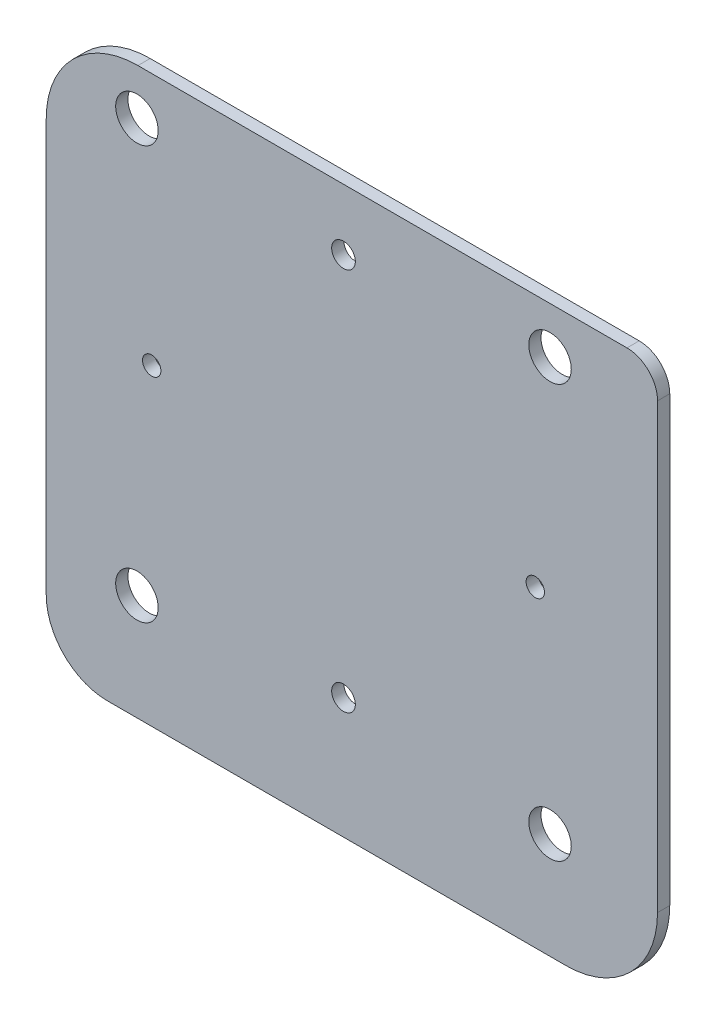
from build123d import *

# Parameters (mm, degrees)
BOSS_EXTRUDE1_DEPTH       = 1.6
CUT_EXTRUDE3_REACH        = 3.6
SKETCH3_R                 = 1.55
SKETCH3_R_2               = 1.2
CUT_EXTRUDE4_REACH        = 3.6
PRESS_FIT_NUT_LOCATIONS_R = 2.78


with BuildPart() as part:
    # Outline → Boss-Extrude1 (new body)
    with BuildSketch(Plane.XY):
        with BuildLine():
            Line((-38.9, 21.1), (-38.9, -32.9))
            ThreePointArc((-38.9, -32.9), (-36.556854249, -38.556854249), (-30.9, -40.9))
            Line((-30.9, -40.9), (29.1, -40.9))
            ThreePointArc((29.1, -40.9), (37.585281374, -37.385281374), (41.1, -28.9))
            Line((41.1, -28.9), (41.1, 29.1))
            ThreePointArc((41.1, 29.1), (39.928427125, 31.928427125), (37.1, 33.1))
            Line((37.1, 33.1), (-26.9, 33.1))
            ThreePointArc((-26.9, 33.1), (-35.385281374, 29.585281374), (-38.9, 21.1))
        make_face()
    extrude(amount=BOSS_EXTRUDE1_DEPTH)

    # Sketch3 → Cut-Extrude3 (cut, up to next)
    with BuildSketch(Plane.XY.offset(1.6), mode=Mode.PRIVATE) as cut_extrude3_sk1:
        with Locations((-6.677e-06, 25.099991446)):
            Circle(SKETCH3_R)
    cut_extrude3_tool1 = extrude(cut_extrude3_sk1.sketch, amount=-CUT_EXTRUDE3_REACH, mode=Mode.PRIVATE) & part.part
    add(cut_extrude3_tool1.solids().sort_by_distance((-7e-06, 25.099991, 1.6))[0], mode=Mode.SUBTRACT)
    # Sketch3 → Cut-Extrude3 (cut, up to next)
    with BuildSketch(Plane.XY.offset(1.6), mode=Mode.PRIVATE) as cut_extrude3_sk2:
        with Locations((25.099993323, -8.554e-06)):
            Circle(SKETCH3_R_2)
    cut_extrude3_tool2 = extrude(cut_extrude3_sk2.sketch, amount=-CUT_EXTRUDE3_REACH, mode=Mode.PRIVATE) & part.part
    add(cut_extrude3_tool2.solids().sort_by_distance((25.099993, -9e-06, 1.6))[0], mode=Mode.SUBTRACT)
    # Sketch3 → Cut-Extrude3 (cut, up to next)
    with BuildSketch(Plane.XY.offset(1.6), mode=Mode.PRIVATE) as cut_extrude3_sk3:
        with Locations((-6.677e-06, -25.100008554)):
            Circle(SKETCH3_R)
    cut_extrude3_tool3 = extrude(cut_extrude3_sk3.sketch, amount=-CUT_EXTRUDE3_REACH, mode=Mode.PRIVATE) & part.part
    add(cut_extrude3_tool3.solids().sort_by_distance((-7e-06, -25.100009, 1.6))[0], mode=Mode.SUBTRACT)
    # Sketch3 → Cut-Extrude3 (cut, up to next)
    with BuildSketch(Plane.XY.offset(1.6), mode=Mode.PRIVATE) as cut_extrude3_sk4:
        with Locations((-25.100006677, -8.554e-06)):
            Circle(SKETCH3_R_2)
    cut_extrude3_tool4 = extrude(cut_extrude3_sk4.sketch, amount=-CUT_EXTRUDE3_REACH, mode=Mode.PRIVATE) & part.part
    add(cut_extrude3_tool4.solids().sort_by_distance((-25.100007, -9e-06, 1.6))[0], mode=Mode.SUBTRACT)

    # Press Fit Nut Locations → Cut-Extrude4 (cut, up to next)
    with BuildSketch(Plane.XY.offset(1.6), mode=Mode.PRIVATE) as cut_extrude4_sk1:
        with Locations((-27.030733336, 27.030733336)):
            Circle(PRESS_FIT_NUT_LOCATIONS_R)
    cut_extrude4_tool1 = extrude(cut_extrude4_sk1.sketch, amount=-CUT_EXTRUDE4_REACH, mode=Mode.PRIVATE) & part.part
    add(cut_extrude4_tool1.solids().sort_by_distance((-27.030733, 27.030733, 1.6))[0], mode=Mode.SUBTRACT)
    # Press Fit Nut Locations → Cut-Extrude4 (cut, up to next)
    with BuildSketch(Plane.XY.offset(1.6), mode=Mode.PRIVATE) as cut_extrude4_sk2:
        with Locations((27.030733336, 27.030733336)):
            Circle(PRESS_FIT_NUT_LOCATIONS_R)
    cut_extrude4_tool2 = extrude(cut_extrude4_sk2.sketch, amount=-CUT_EXTRUDE4_REACH, mode=Mode.PRIVATE) & part.part
    add(cut_extrude4_tool2.solids().sort_by_distance((27.030733, 27.030733, 1.6))[0], mode=Mode.SUBTRACT)
    # Press Fit Nut Locations → Cut-Extrude4 (cut, up to next)
    with BuildSketch(Plane.XY.offset(1.6), mode=Mode.PRIVATE) as cut_extrude4_sk3:
        with Locations((-27.030733336, -27.030733336)):
            Circle(PRESS_FIT_NUT_LOCATIONS_R)
    cut_extrude4_tool3 = extrude(cut_extrude4_sk3.sketch, amount=-CUT_EXTRUDE4_REACH, mode=Mode.PRIVATE) & part.part
    add(cut_extrude4_tool3.solids().sort_by_distance((-27.030733, -27.030733, 1.6))[0], mode=Mode.SUBTRACT)
    # Press Fit Nut Locations → Cut-Extrude4 (cut, up to next)
    with BuildSketch(Plane.XY.offset(1.6), mode=Mode.PRIVATE) as cut_extrude4_sk4:
        with Locations((27.030733336, -27.030733336)):
            Circle(PRESS_FIT_NUT_LOCATIONS_R)
    cut_extrude4_tool4 = extrude(cut_extrude4_sk4.sketch, amount=-CUT_EXTRUDE4_REACH, mode=Mode.PRIVATE) & part.part
    add(cut_extrude4_tool4.solids().sort_by_distance((27.030733, -27.030733, 1.6))[0], mode=Mode.SUBTRACT)


solid = part.part
